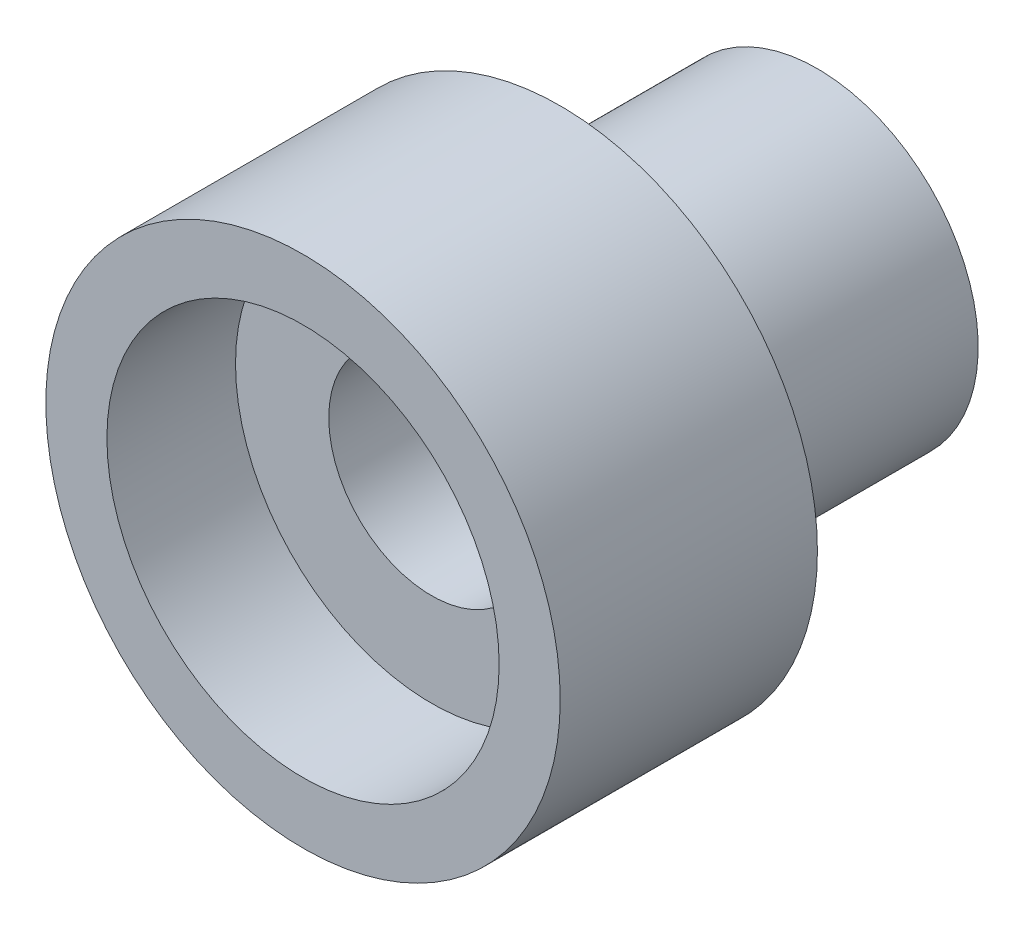
from build123d import *

# Parameters (mm, degrees)
SKETCH_1_R               = 4
EXTRUDE_1_DEPTH          = 4
SKETCH_4_R               = 2.5
EXTRUDE_2_DEPTH          = 4
SKETCH_2_R               = 1.6
CUT_EXTRUDE_1_DEPTH      = 4
CUT_EXTRUDE_1_DEPTH_BACK = 3
SKETCH_3_R               = 3.05
CUT_EXTRUDE_2_DEPTH      = 2


with BuildPart() as part:
    # 草图1 → 凸台-拉伸1 (new body)
    with BuildSketch(Plane.XY):
        Circle(SKETCH_1_R)
    extrude(amount=EXTRUDE_1_DEPTH)

    # 草图4 → 凸台-拉伸2 (add)
    with BuildSketch(Plane(origin=(0, 0, 0), x_dir=(-1, 0, 0), z_dir=(0, 0, -1))):
        Circle(SKETCH_4_R)
    extrude(amount=EXTRUDE_2_DEPTH)

    # 草图2 → 切除-拉伸1 (cut, two sides)
    with BuildSketch(Plane(origin=(0, 0, 0), x_dir=(-1, 0, 0), z_dir=(0, 0, -1))) as cut_extrude_1_sk:
        Circle(SKETCH_2_R)
    extrude(amount=CUT_EXTRUDE_1_DEPTH, mode=Mode.SUBTRACT)
    extrude(cut_extrude_1_sk.sketch, amount=-CUT_EXTRUDE_1_DEPTH_BACK, mode=Mode.SUBTRACT)

    # 草图3 → 切除-拉伸2 (cut)
    with BuildSketch(Plane.XY.offset(4)):
        Circle(SKETCH_3_R)
    extrude(amount=-CUT_EXTRUDE_2_DEPTH, mode=Mode.SUBTRACT)


solid = part.part
